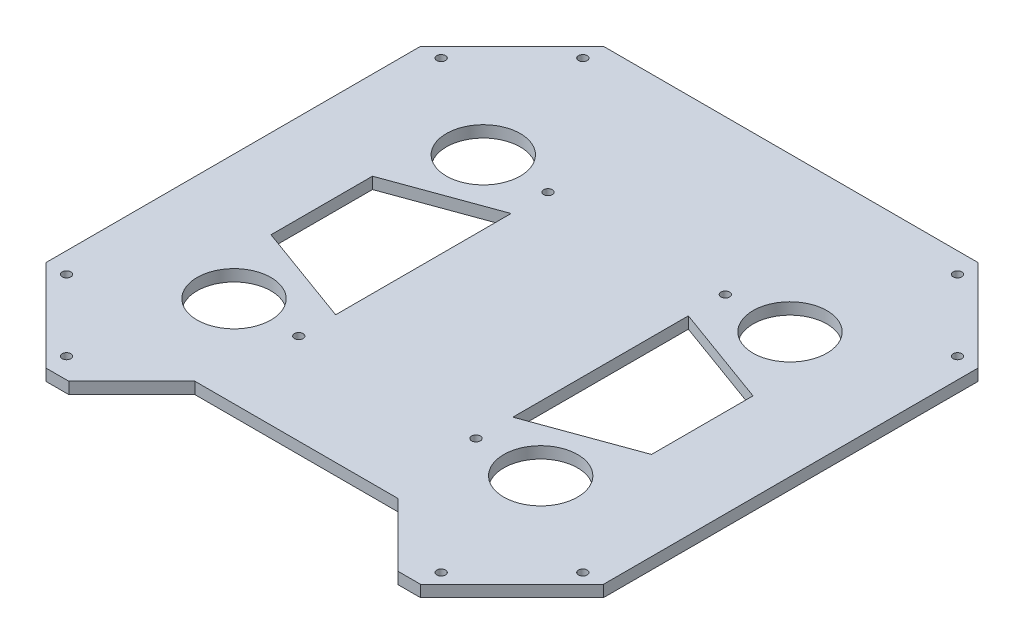
from build123d import *

# Parameters (mm, degrees)
SKETCH1_R           = 40.4
SKETCH1_R_2         = 4.7625
BOSS_EXTRUDE1_DEPTH = 12.7
CUT_EXTRUDE1_DEPTH  = 5000
SKETCH3_R           = 4.7625
CUT_EXTRUDE2_DEPTH  = 5000
CUT_EXTRUDE3_DEPTH  = 20


with BuildPart() as part:
    # Sketch1 → Boss-Extrude1 (new body)
    with BuildSketch(Plane(origin=(0, 0, 0), x_dir=(1, 0, 0), z_dir=(0, 1, 0))):
        Polygon((205, 0), (305, 100), (305, 510), (205, 610), (-205, 610), (-305, 510), (-305, 100), (-205, 0), align=None)
        with Locations((-167.82128445, 168.589357775)):
            Circle(SKETCH1_R, mode=Mode.SUBTRACT)
        with Locations((-97, 168.589357775)):
            Circle(SKETCH1_R_2, mode=Mode.SUBTRACT)
        with Locations((97, 168.589357775)):
            Circle(SKETCH1_R_2, mode=Mode.SUBTRACT)
        with Locations((167.82128445, 168.589357775)):
            Circle(SKETCH1_R, mode=Mode.SUBTRACT)
        with Locations((-167.82128445, 441.410642225)):
            Circle(SKETCH1_R, mode=Mode.SUBTRACT)
        with Locations((-97, 441.410642225)):
            Circle(SKETCH1_R_2, mode=Mode.SUBTRACT)
        with Locations((97, 441.410642225)):
            Circle(SKETCH1_R_2, mode=Mode.SUBTRACT)
        with Locations((167.82128445, 441.410642225)):
            Circle(SKETCH1_R, mode=Mode.SUBTRACT)
    extrude(amount=BOSS_EXTRUDE1_DEPTH)

    # Sketch2 → Cut-Extrude1 (cut)
    with BuildSketch(Plane(origin=(0, 12.7, 0), x_dir=(1, 0, 0), z_dir=(0, 1, 0))):
        Polygon((-111, 69), (-180, 0), (180, 0), (111, 69), align=None)
    extrude(amount=-CUT_EXTRUDE1_DEPTH, mode=Mode.SUBTRACT)

    # Sketch3 → Cut-Extrude2 (cut)
    with BuildSketch(Plane(origin=(0, 12.7, 0), x_dir=(1, 0, 0), z_dir=(0, 1, 0))):
        with Locations((-205, 22.45771137)):
            Circle(SKETCH3_R)
        with Locations((205, 22.45771137)):
            Circle(SKETCH3_R)
        with Locations((-282.54228863, 100)):
            Circle(SKETCH3_R)
        with Locations((282.54228863, 100)):
            Circle(SKETCH3_R)
        with Locations((282.54228863, 510)):
            Circle(SKETCH3_R)
        with Locations((205, 587.54228863)):
            Circle(SKETCH3_R)
        with Locations((-205, 587.54228863)):
            Circle(SKETCH3_R)
        with Locations((-282.54228863, 510)):
            Circle(SKETCH3_R)
    extrude(amount=-CUT_EXTRUDE2_DEPTH, mode=Mode.SUBTRACT)

    # Sketch4 → Cut-Extrude3 (cut)
    with BuildSketch(Plane(origin=(0, 12.7, 0), x_dir=(1, 0, 0), z_dir=(0, 1, 0))):
        Polygon((-208.22128445, 360.529405268), (-97, 401.010642225), (-97, 208.989357775), (-208.22128445, 249.470594732), align=None)
        Polygon((208.22128445, 249.470594732), (208.22128445, 360.529405268), (97, 401.010642225), (97, 208.989357775), align=None)
    extrude(amount=-CUT_EXTRUDE3_DEPTH, mode=Mode.SUBTRACT)


solid = part.part
